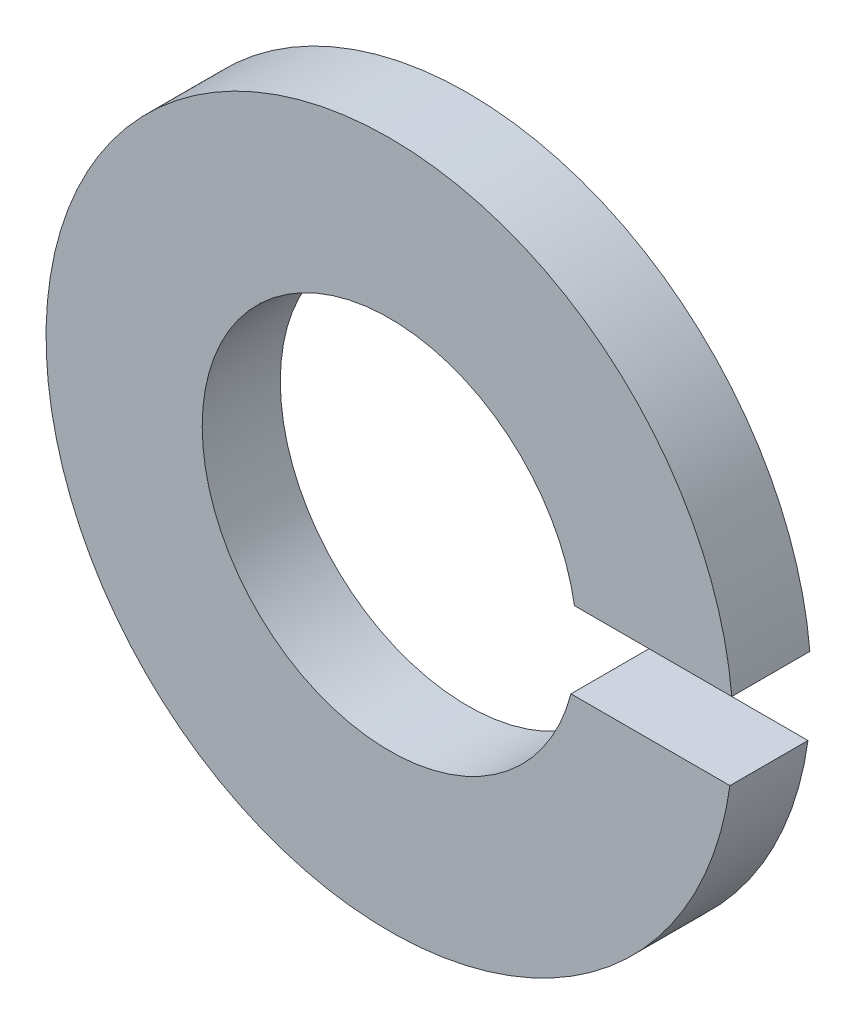
from build123d import *

# Parameters (mm, degrees)
BOSS_EXTRUDE1_DEPTH = 0.5


with BuildPart() as part:
    # Sketch1 → Boss-Extrude1 (new body)
    with BuildSketch(Plane.XY):
        with BuildLine():
            ThreePointArc((2.191091812, 0.197779353), (-2.199372026, 0.052561313), (2.179142648, -0.302220647))
            Line((2.179142648, -0.302220647), (1.161319371, -0.302220647))
            ThreePointArc((1.161319371, -0.302220647), (-1.198811502, 0.053394588), (1.183589172, 0.197779353))
            Line((1.183589172, 0.197779353), (2.191091812, 0.197779353))
        make_face()
    extrude(amount=BOSS_EXTRUDE1_DEPTH)


solid = part.part
